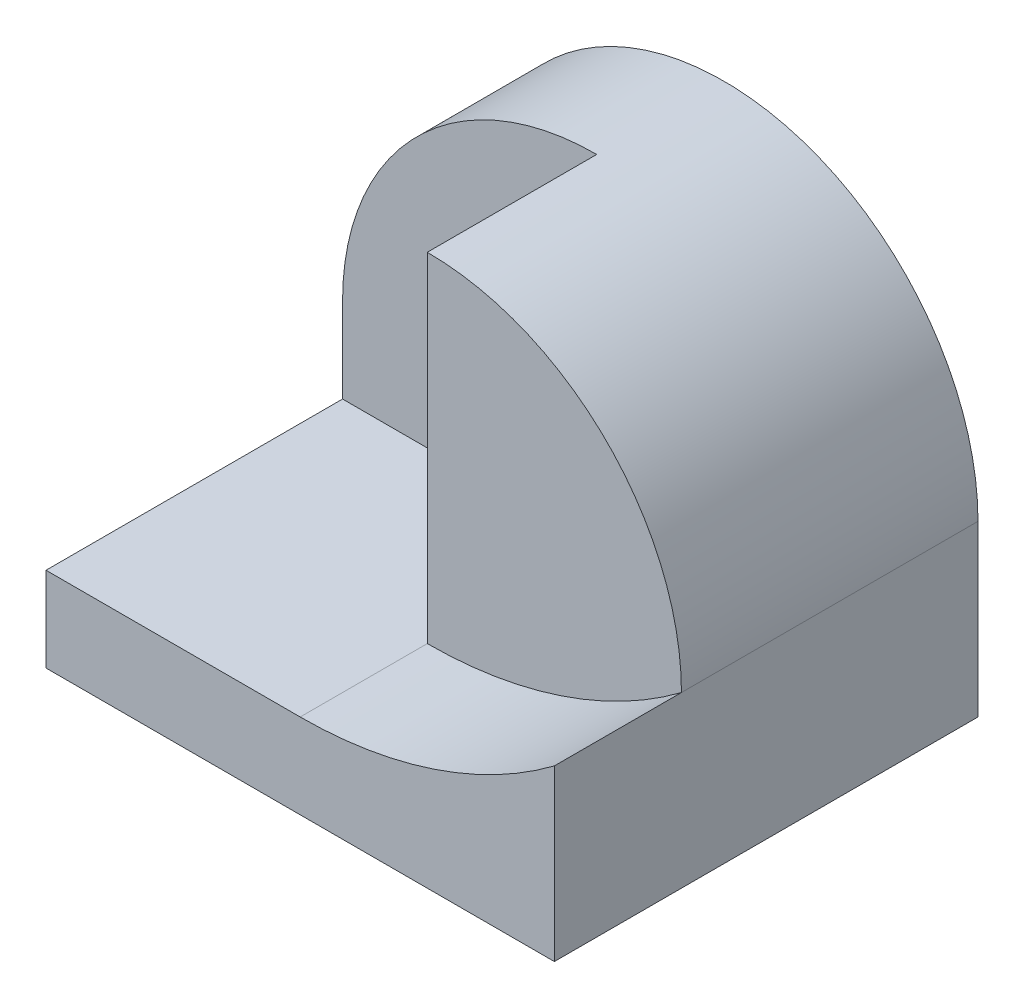
from build123d import *

# Parameters (mm, degrees)
SKETCH2_W            = 60
SKETCH2_H            = 10
BOSS_EXTRUDE10_DEPTH = 50
BOSS_EXTRUDE11_DEPTH = 15
BOSS_EXTRUDE12_DEPTH = 35
BOSS_EXTRUDE14_DEPTH = 50
BOSS_EXTRUDE18_DEPTH = 35
SKETCH14_W           = 30
SKETCH14_H           = 10
CUT_EXTRUDE1_DEPTH   = 20


with BuildPart() as part:
    # Sketch2 → Boss-Extrude10 (new body)
    with BuildSketch(Plane.XY):
        with Locations((30, 5)):
            Rectangle(SKETCH2_W, SKETCH2_H)
    extrude(amount=BOSS_EXTRUDE10_DEPTH)

    # Sketch12 → Boss-Extrude14 (add)
    with BuildSketch(Plane.XY.offset(50)):
        with BuildLine():
            Line((30, 10), (60, 10))
            Line((60, 10), (60, 20))
            ThreePointArc((60, 20), (45.811388301, 12.565835097), (30, 10))
        make_face()
    extrude(amount=-BOSS_EXTRUDE14_DEPTH)



with BuildPart() as body_2:
    # Sketch9 → Boss-Extrude11 (new body)
    with BuildSketch(Plane(origin=(0, 0, 0), x_dir=(-1, 0, 0), z_dir=(0, 0, -1))):
        with BuildLine():
            Line((-30, 50), (-30, 20))
            Line((-30, 20), (0, 20))
            ThreePointArc((0, 20), (-8.786796564, 41.213203436), (-30, 50))
        make_face()
    extrude(amount=-BOSS_EXTRUDE11_DEPTH)

    # Sketch10 → Boss-Extrude12 (add)
    with BuildSketch(Plane(origin=(0, 0, 0), x_dir=(-1, 0, 0), z_dir=(0, 0, -1))):
        with BuildLine():
            Line((-60, 20), (-30, 20))
            Line((-30, 20), (-30, 50))
            ThreePointArc((-30, 50), (-51.213203436, 41.213203436), (-60, 20))
        make_face()
    extrude(amount=-BOSS_EXTRUDE12_DEPTH)


with BuildPart() as part_1:
    add(part.part)

    add(body_2.part)  # Boss-Extrude18 merges body 2
    # Sketch13 → Boss-Extrude18 (add)
    with BuildSketch(Plane(origin=(0, 0, 0), x_dir=(-1, 0, 0), z_dir=(0, 0, -1))):
        with BuildLine():
            Line((0, 20), (-60, 20))
            ThreePointArc((-60, 20), (-45.811388301, 12.565835097), (-30, 10))
            Line((-30, 10), (0, 10))
            Line((0, 10), (0, 20))
        make_face()
    extrude(amount=-BOSS_EXTRUDE18_DEPTH)

    # Sketch14 → Cut-Extrude1 (cut)
    with BuildSketch(Plane.XY.offset(35)):
        with Locations((15, 15)):
            Rectangle(SKETCH14_W, SKETCH14_H)
    extrude(amount=-CUT_EXTRUDE1_DEPTH, mode=Mode.SUBTRACT)


solid = part_1.part
